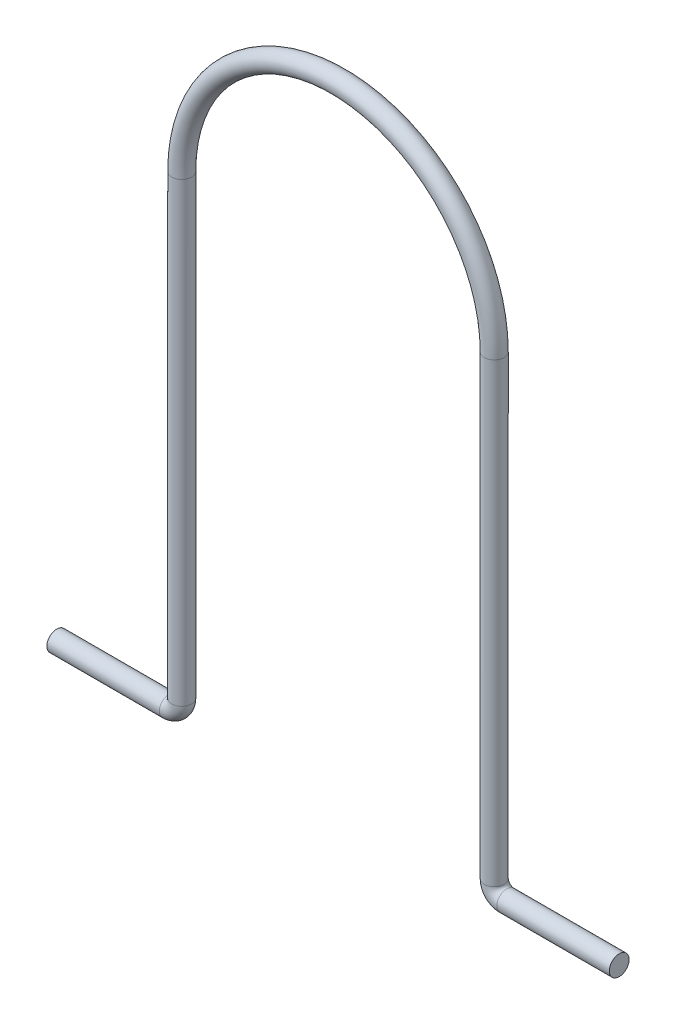
from build123d import *

# Parameters (mm, degrees)
SKETCH2_R = 1.5875


with BuildPart() as part:
    # Sweep1: sweep along a path in Sketch1
    with BuildLine(Plane.XY) as sweep1_path:
        Line((0, 0), (18, 0))
        ThreePointArc((18, 0), (19.414213562, 0.585786438), (20, 2))
        Line((20, 2), (20, 75))
        ThreePointArc((20, 75), (45, 100), (70, 75))
        Line((70, 75), (70, 2))
        ThreePointArc((70, 2), (70.585786438, 0.585786438), (72, 0))
        Line((72, 0), (90, 0))
    # Sketch2 → Sweep1 (sweep)
    with BuildSketch(Plane(origin=(0, 0, 0), x_dir=(0, 0, -1), z_dir=(1, 0, 0))):
        Circle(SKETCH2_R)
    sweep(path=sweep1_path.line)


solid = part.part
